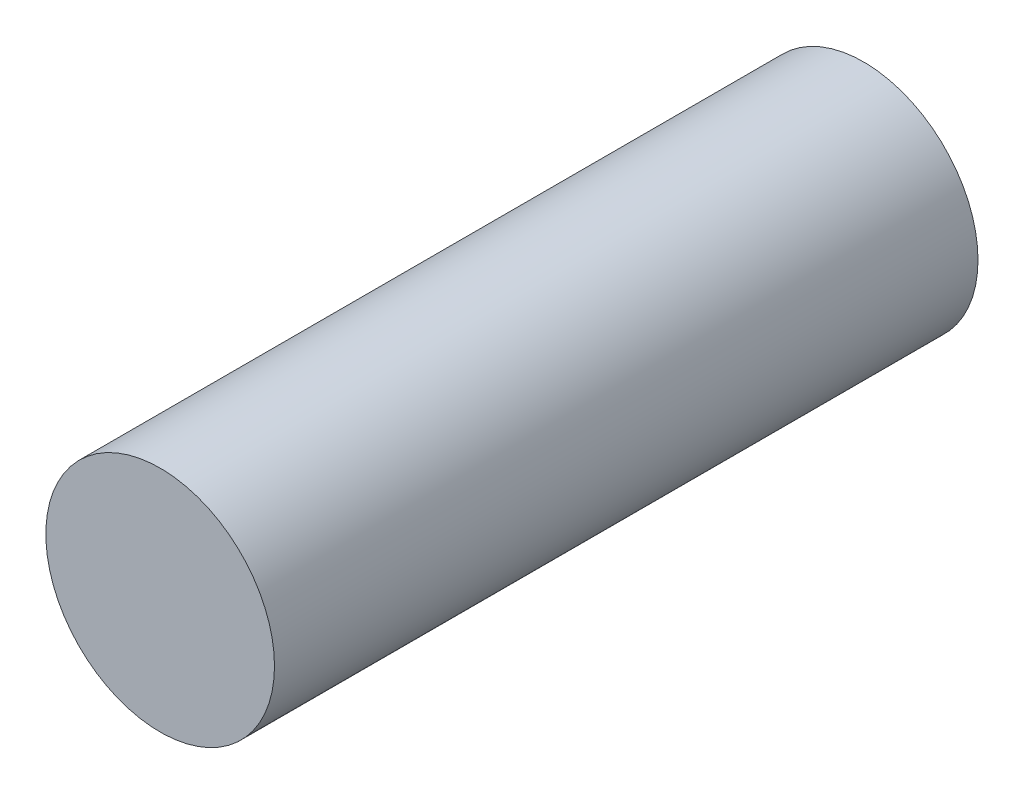
from build123d import *

# Parameters (mm, degrees)
SKETCH1_R           = 6.5
BOSS_EXTRUDE1_DEPTH = 40


with BuildPart() as part:
    # Sketch1 → Boss-Extrude1 (new body)
    with BuildSketch(Plane.XY):
        Circle(SKETCH1_R)
    extrude(amount=BOSS_EXTRUDE1_DEPTH)


solid = part.part
